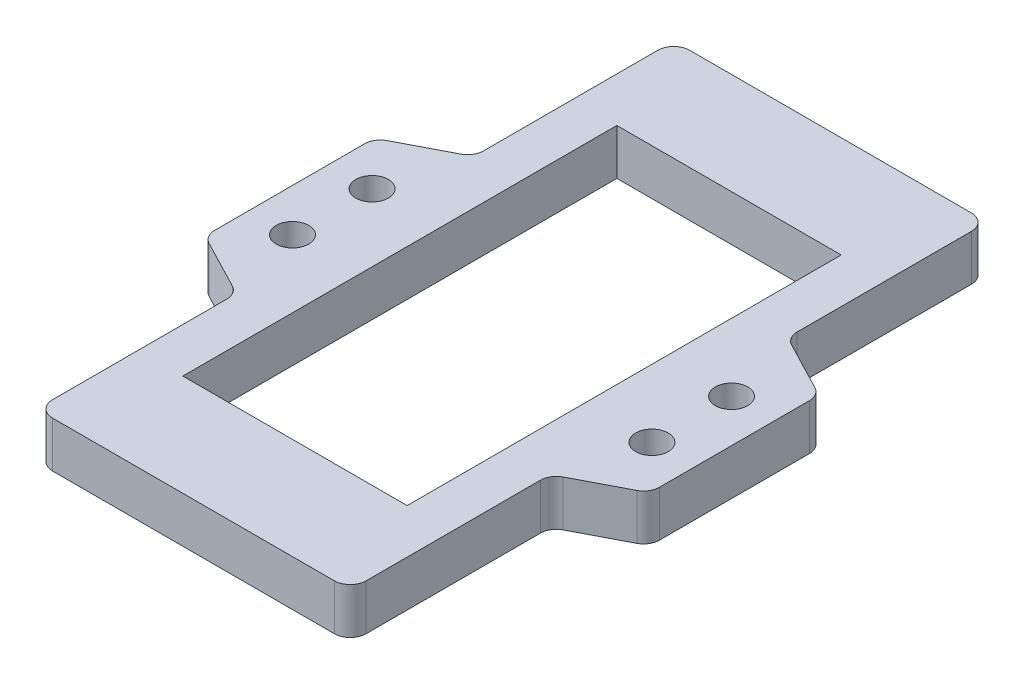
from build123d import *

# Parameters (mm, degrees)
SKETCH1_W                                = 70.945719932
SKETCH1_H                                = 101.6
BOSS_EXTRUDE1_DEPTH                      = 7.3152
F_6_0_204_DIAMETER_HOLE1_D               = 5.1816
FILLET1_R                                = 2.54
CUT_EXTRUDE1_DEPTH                       = 8.3152
FILLET2_R                                = 2.54
MIRROR4_AT_THE_SECOND_PLANE_COPY_1_DEPTH = 8.3152
FILLET3_R                                = 2.54
SKETCH5_W                                = 35.77
SKETCH5_H                                = 69.215
CUT_EXTRUDE2_DEPTH                       = 8.3152


with BuildPart() as part:
    # Sketch1 → Boss-Extrude1 (new body)
    with BuildSketch(Plane(origin=(0, 0, 0), x_dir=(1, 0, 0), z_dir=(0, 1, 0))):
        Rectangle(SKETCH1_W, SKETCH1_H)
    extrude(amount=BOSS_EXTRUDE1_DEPTH)

    # 6 _0.204_ Diameter Hole1 (through all)
    with Locations(Plane(origin=(-28.662459966, 7.3152, 6.35), x_dir=(0, 0, 1), z_dir=(0, 1, 0))):
        with Locations((0, 0), (-12.7, 0)):
            f_6_0_204_diameter_hole1 = Hole(F_6_0_204_DIAMETER_HOLE1_D / 2)

    # Mirror2: 6 _0.204_ Diameter Hole1 across plane
    add(f_6_0_204_diameter_hole1.mirror(Plane(origin=(0, 0, 0), x_dir=(0, 0, 1), z_dir=(1, 0, 0))), mode=Mode.SUBTRACT)

    # Fillet1
    fillet1_edges = [part.edges().sort_by_distance(p)[0] for p in [
        (-35.472859966, 3.6576, -50.8),
        (35.472859966, 3.6576, -50.8),
        (35.472859966, 3.6576, 50.8),
        (-35.472859966, 3.6576, 50.8),
    ]]
    fillet(fillet1_edges, radius=FILLET1_R)

    # Sketch4 → Cut-Extrude1 (cut, through all)
    with BuildSketch(Plane(origin=(0, 7.3152, 0), x_dir=(1, 0, 0), z_dir=(0, 1, 0))):
        Polygon((-35.472859966, 13.49), (-25.007259027, 18.930947869), (-25.007259027, 50.8), (-35.472859966, 50.8), align=None)
    cut_extrude1 = extrude(amount=-CUT_EXTRUDE1_DEPTH, mode=Mode.SUBTRACT)

    # Fillet2
    fillet2_edges = [part.edges().sort_by_distance(p)[0] for p in [
        (-35.472859966, 3.6576, -13.49),
        (-25.007259027, 3.6576, -50.8),
        (-25.007259027, 3.6576, -18.930947869),
    ]]
    fillet(fillet2_edges, radius=FILLET2_R)

    # Mirror4: Cut-Extrude1 across plane
    add(cut_extrude1.mirror(Plane(origin=(0, 0, 0), x_dir=(0, 0, 1), z_dir=(1, 0, 0))), mode=Mode.SUBTRACT)

    # Mirror4 at the second plane: Cut-Extrude1 across plane
    add(cut_extrude1.mirror(Plane.XY), mode=Mode.SUBTRACT)

    # Mirror4 at the second plane copy 1 sketc → Mirror4 at the second plane copy 1 (cut, through all)
    with BuildSketch(Plane(origin=(0, 7.3152, 0), x_dir=(-1, 0, 0), z_dir=(0, 1, 0))):
        Polygon((-35.472859966, 13.49), (-25.007259027, 18.930947869), (-25.007259027, 50.8), (-35.472859966, 50.8), align=None)
    extrude(amount=-MIRROR4_AT_THE_SECOND_PLANE_COPY_1_DEPTH, mode=Mode.SUBTRACT)

    # Fillet3
    fillet3_edges = [part.edges().sort_by_distance(p)[0] for p in [
        (-25.007259027, 3.6576, 50.8),
        (-35.472859966, 3.6576, 13.49),
        (-25.007259027, 3.6576, 18.930947869),
        (25.007259027, 3.6576, -50.8),
        (35.472859966, 3.6576, -13.49),
        (25.007259027, 3.6576, -18.930947869),
        (35.472859966, 3.6576, 13.49),
        (25.007259027, 3.6576, 50.8),
        (25.007259027, 3.6576, 18.930947869),
    ]]
    fillet(fillet3_edges, radius=FILLET3_R)

    # Sketch5 → Cut-Extrude2 (cut, through all)
    with BuildSketch(Plane(origin=(0, 7.3152, 0), x_dir=(1, 0, 0), z_dir=(0, 1, 0))):
        Rectangle(SKETCH5_W, SKETCH5_H)
    extrude(amount=-CUT_EXTRUDE2_DEPTH, mode=Mode.SUBTRACT)


solid = part.part
